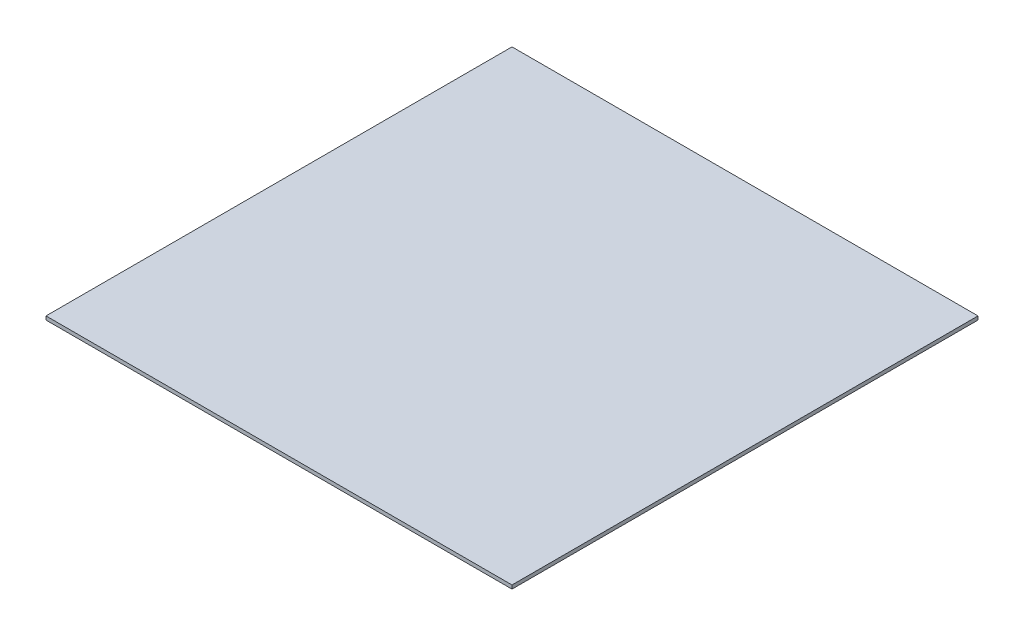
from build123d import *

# Parameters (mm, degrees)
SKETCH1_W           = 1281.27748751
SKETCH1_H           = 1281.27748751
BOSS_EXTRUDE1_DEPTH = 10


with BuildPart() as part:
    # Sketch1 → Boss-Extrude1 (new body)
    with BuildSketch(Plane(origin=(0, 0, 0), x_dir=(1, 0, 0), z_dir=(0, 1, 0))):
        Rectangle(SKETCH1_W, SKETCH1_H)
    extrude(amount=BOSS_EXTRUDE1_DEPTH)


solid = part.part
